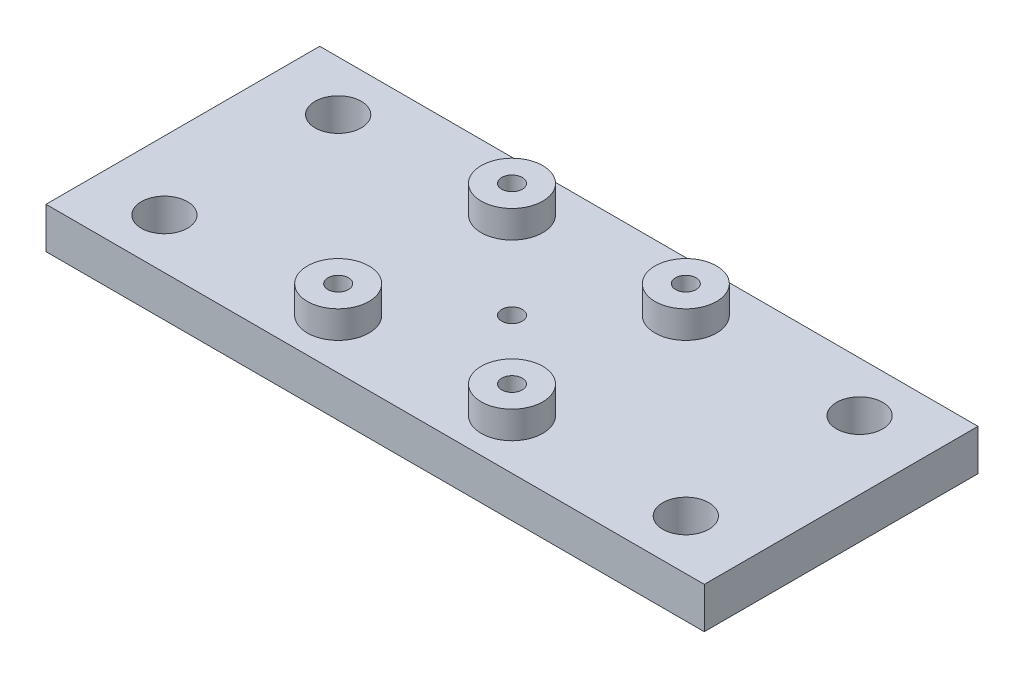
from build123d import *

# Parameters (mm, degrees)
SKETCH2_W                 = 96.2
SKETCH2_H                 = 40
SKETCH2_R                 = 1.5
SKETCH2_R_2               = 3.3734375
BOSS_EXTRUDE1_DEPTH       = 6
SKETCH3_R                 = 4.5
SKETCH3_R_2               = 1.5
BOSS_EXTRUDE2_DEPTH       = 4
MIRROR2_COPY_1_SKETCH_R   = 4.5
MIRROR2_COPY_1_SKETCH_R_2 = 1.5
MIRROR2_COPY_1_DEPTH      = 4
SKETCH5_R                 = 2.75
CUT_EXTRUDE1_DEPTH        = 3.3


with BuildPart() as part:
    # Sketch2 → Boss-Extrude1 (new body)
    with BuildSketch(Plane(origin=(0, 0, 0), x_dir=(1, 0, 0), z_dir=(0, 1, 0))):
        with Locations((70.631888672, 52.455394598)):
            Rectangle(SKETCH2_W, SKETCH2_H)
        with Locations((57.931888672, 39.755394598)):
            Circle(SKETCH2_R, mode=Mode.SUBTRACT)
        with Locations((83.331888672, 39.755394598)):
            Circle(SKETCH2_R, mode=Mode.SUBTRACT)
        with Locations((70.631888672, 52.455394598)):
            Circle(SKETCH2_R, mode=Mode.SUBTRACT)
        with Locations((57.931888672, 65.155394598)):
            Circle(SKETCH2_R, mode=Mode.SUBTRACT)
        with Locations((83.331888672, 65.155394598)):
            Circle(SKETCH2_R, mode=Mode.SUBTRACT)
        with Locations((108.731888672, 65.155394598)):
            Circle(SKETCH2_R_2, mode=Mode.SUBTRACT)
        with Locations((108.731888672, 39.755394598)):
            Circle(SKETCH2_R_2, mode=Mode.SUBTRACT)
        with Locations((32.531888672, 65.155394598)):
            Circle(SKETCH2_R_2, mode=Mode.SUBTRACT)
        with Locations((32.531888672, 39.755394598)):
            Circle(SKETCH2_R_2, mode=Mode.SUBTRACT)
    extrude(amount=BOSS_EXTRUDE1_DEPTH)

    # Sketch3 → Boss-Extrude2 (add)
    with BuildSketch(Plane(origin=(0, 6, 0), x_dir=(1, 0, 0), z_dir=(0, 1, 0))):
        with Locations((57.931888672, 65.155394598)):
            Circle(SKETCH3_R)
        with Locations((57.931888672, 65.155394598)):
            Circle(SKETCH3_R_2, mode=Mode.SUBTRACT)
    boss_extrude2 = extrude(amount=BOSS_EXTRUDE2_DEPTH)

    # Mirror1: Boss-Extrude2 across plane
    add(boss_extrude2.mirror(Plane.ZY.offset(-70.631888672)))

    # Mirror2: Boss-Extrude2 across plane
    add(boss_extrude2.mirror(Plane(origin=(0, 0, -52.455394598), x_dir=(1, 0, 0), z_dir=(0, 0, -1))))

    # Mirror2 copy 1 sketch → Mirror2 copy 1 (add)
    with BuildSketch(Plane(origin=(141.263777343, 6, -104.910789197), x_dir=(-1, 0, 0), z_dir=(0, 1, 0))):
        with Locations((57.931888672, 65.155394598)):
            Circle(MIRROR2_COPY_1_SKETCH_R)
        with Locations((57.931888672, 65.155394598)):
            Circle(MIRROR2_COPY_1_SKETCH_R_2, mode=Mode.SUBTRACT)
    extrude(amount=MIRROR2_COPY_1_DEPTH)

    # Sketch5 → Cut-Extrude1 (cut)
    with BuildSketch(Plane.XZ):
        with Locations((70.631888672, -52.455394598)):
            Circle(SKETCH5_R)
    extrude(amount=-CUT_EXTRUDE1_DEPTH, mode=Mode.SUBTRACT)


solid = part.part
